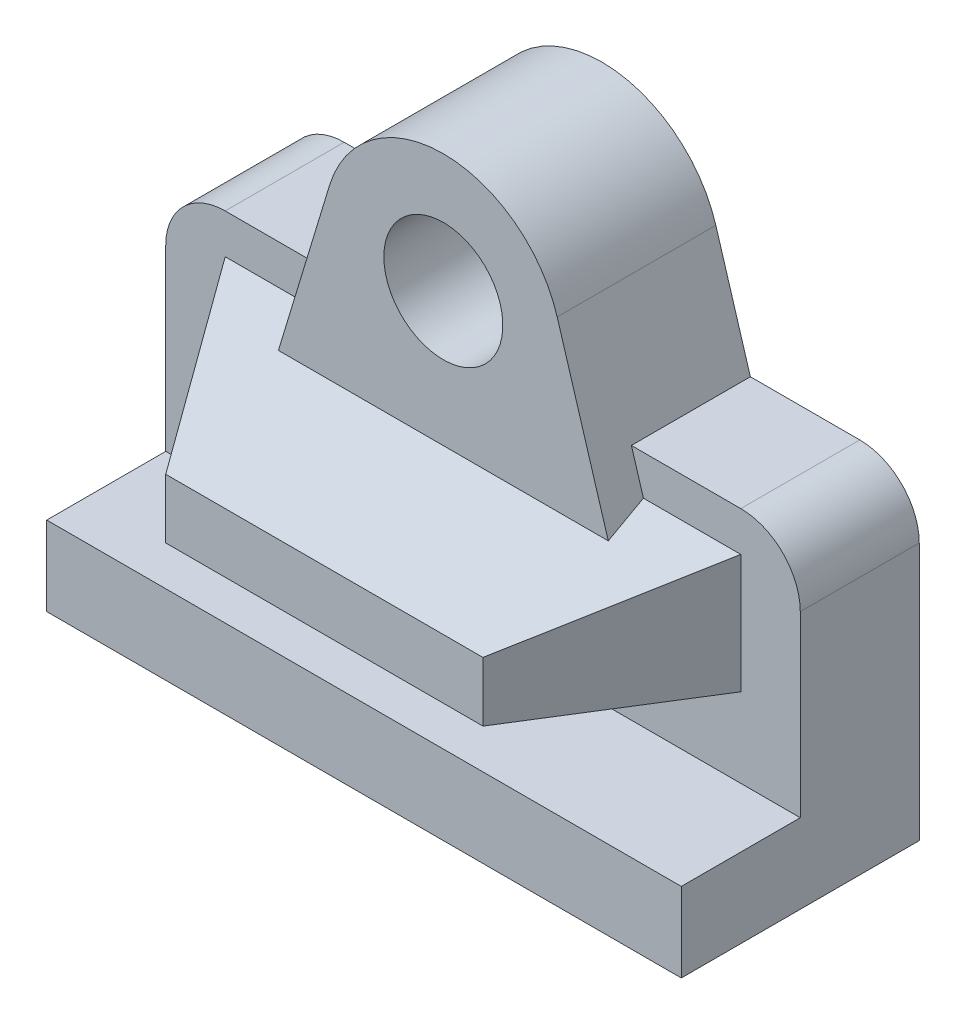
from build123d import *

# Parameters (mm, degrees)
SKETCH1_R           = 9.525
BOSS_EXTRUDE1_DEPTH = 19.05
SKETCH1_3_R         = 9.525
BOSS_EXTRUDE2_DEPTH = 25.4
SKETCH1_4_W         = 101.6
SKETCH1_4_H         = 12.7
BOSS_EXTRUDE3_DEPTH = 38.1


with BuildPart() as part:
    # Sketch1 → Boss-Extrude1 (new body)
    with BuildSketch(Plane.XY):
        with BuildLine():
            Line((-50.8, 41.275), (-50.8, 12.7))
            Line((-50.8, 12.7), (50.8, 12.7))
            Line((50.8, 12.7), (50.8, 41.275))
            ThreePointArc((50.8, 41.275), (48.010192091, 48.010192091), (41.275, 50.8))
            Line((41.275, 50.8), (23.759524406, 50.8))
            Line((23.759524406, 50.8), (18.229762203, 69.029762203))
            ThreePointArc((18.229762203, 69.029762203), (0, 82.55), (-18.229762203, 69.029762203))
            Line((-18.229762203, 69.029762203), (-23.759524406, 50.8))
            Line((-23.759524406, 50.8), (-41.275, 50.8))
            ThreePointArc((-41.275, 50.8), (-48.010192091, 48.010192091), (-50.8, 41.275))
        make_face()
        with Locations((0, 63.5)):
            Circle(SKETCH1_R, mode=Mode.SUBTRACT)
    extrude(amount=BOSS_EXTRUDE1_DEPTH)

    # Sketch1_3 → Boss-Extrude2 (add)
    with BuildSketch(Plane.XY):
        with BuildLine():
            Line((-18.229762203, 69.029762203), (-28.575, 34.925))
            Line((-28.575, 34.925), (28.575, 34.925))
            Line((28.575, 34.925), (18.229762203, 69.029762203))
            ThreePointArc((18.229762203, 69.029762203), (0, 82.55), (-18.229762203, 69.029762203))
        make_face()
        with Locations((0, 63.5)):
            Circle(SKETCH1_3_R, mode=Mode.SUBTRACT)
    extrude(amount=BOSS_EXTRUDE2_DEPTH)

    # Sketch1_4 → Boss-Extrude3 (add)
    with BuildSketch(Plane.XY):
        with Locations((0, 6.35)):
            Rectangle(SKETCH1_4_W, SKETCH1_4_H)
    extrude(amount=BOSS_EXTRUDE3_DEPTH)

    # Sketch2 → Loft1 section 0
    with BuildSketch(Plane.XY.offset(19.05)):
        with BuildLine():
            Line((-41.275, 44.45), (41.275, 44.45))
            Line((41.275, 44.45), (41.275, 25.4))
            Line((41.275, 25.4), (-41.275, 25.4))
            Line((-41.275, 25.4), (-41.275, 44.45))
        make_face()
    # Sketch3 → Loft1 section 1
    with BuildSketch(Plane.XY.offset(44.45)):
        with BuildLine():
            Line((-25.4, 25.4), (25.4, 25.4))
            Line((25.4, 25.4), (25.4, 34.925))
            Line((25.4, 34.925), (-25.4, 34.925))
            Line((-25.4, 34.925), (-25.4, 25.4))
        make_face()
    loft()


solid = part.part
